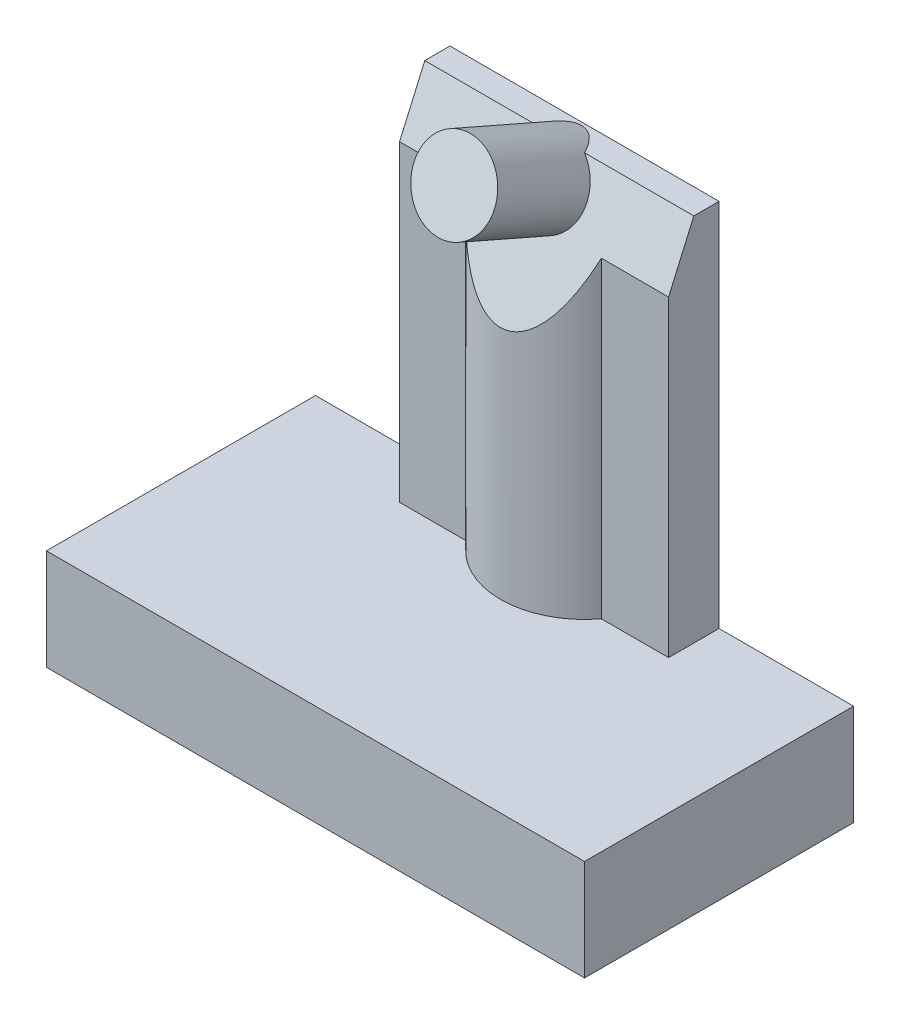
from build123d import *

# Parameters (mm, degrees)
SKETCH1_W                       = 16
SKETCH1_H                       = 8
BOSS_EXTRUDE1_DEPTH             = 3
SHELL1_T                        = -1
BOSS_EXTRUDE2_DEPTH             = 11
CUT_EXTRUDE1_DEPTH              = 13
SKETCH4_R                       = 1.2
BOSS_EXTRUDE3_DEPTH             = 3
BOSS_EXTRUDE3_DIRECTION_2_REACH = 8.299


with BuildPart() as part:
    # Sketch1 → Boss-Extrude1 (new body)
    with BuildSketch(Plane(origin=(0, 0, 0), x_dir=(1, 0, 0), z_dir=(0, 1, 0))):
        Rectangle(SKETCH1_W, SKETCH1_H)
    extrude(amount=BOSS_EXTRUDE1_DEPTH)

    # Shell1
    shell1_openings = [part.faces().sort_by_distance(p)[0] for p in [
        (0, 0, 0),
    ]]
    offset(amount=SHELL1_T, openings=shell1_openings, kind=Kind.INTERSECTION)

    # Sketch2 → Boss-Extrude2 (add)
    with BuildSketch(Plane(origin=(0, 3, 0), x_dir=(1, 0, 0), z_dir=(0, 1, 0))):
        with BuildLine():
            Line((-4, 4), (4, 4))
            Line((4, 4), (4, 2.5))
            Line((4, 2.5), (2, 2.5))
            ThreePointArc((2, 2.5), (0, 1.5), (-2, 2.5))
            Line((-2, 2.5), (-4, 2.5))
            Line((-4, 2.5), (-4, 4))
        make_face()
    extrude(amount=BOSS_EXTRUDE2_DEPTH)

    # Sketch3 → Cut-Extrude1 (cut, through all)
    with BuildSketch(Plane(origin=(4, 0, 0), x_dir=(0, 0, -1), z_dir=(1, 0, 0))):
        Polygon((1.5, 14), (1.5, 10), (3.25, 14), align=None)
    extrude(amount=-CUT_EXTRUDE1_DEPTH, mode=Mode.SUBTRACT)

    # Sketch4 → Boss-Extrude3 (add)
    with BuildSketch(Plane(origin=(0, 1.055737705, 2.413114754), x_dir=(1, 0, 0), z_dir=(0, 0.400818834, 0.916157335))):
        with Locations((0, 13.193478025)):
            Circle(SKETCH4_R)
    extrude(amount=BOSS_EXTRUDE3_DEPTH)

    # Sketch4 → Boss-Extrude3 direction 2 (add, up to next)
    with BuildSketch(Plane(origin=(0, 1.055737705, 2.413114754), x_dir=(1, 0, 0), z_dir=(0, 0.400818834, 0.916157335)), mode=Mode.PRIVATE) as boss_extrude3_direction_2_sk1:
        with Locations((0, 13.193478025)):
            Circle(SKETCH4_R)
    boss_extrude3_direction_2_tool1 = extrude(boss_extrude3_direction_2_sk1.sketch, amount=-BOSS_EXTRUDE3_DIRECTION_2_REACH, mode=Mode.PRIVATE) - part.part
    add(boss_extrude3_direction_2_tool1.solids().sort_by_distance((0, 13.143039, -2.87508))[0])


solid = part.part
